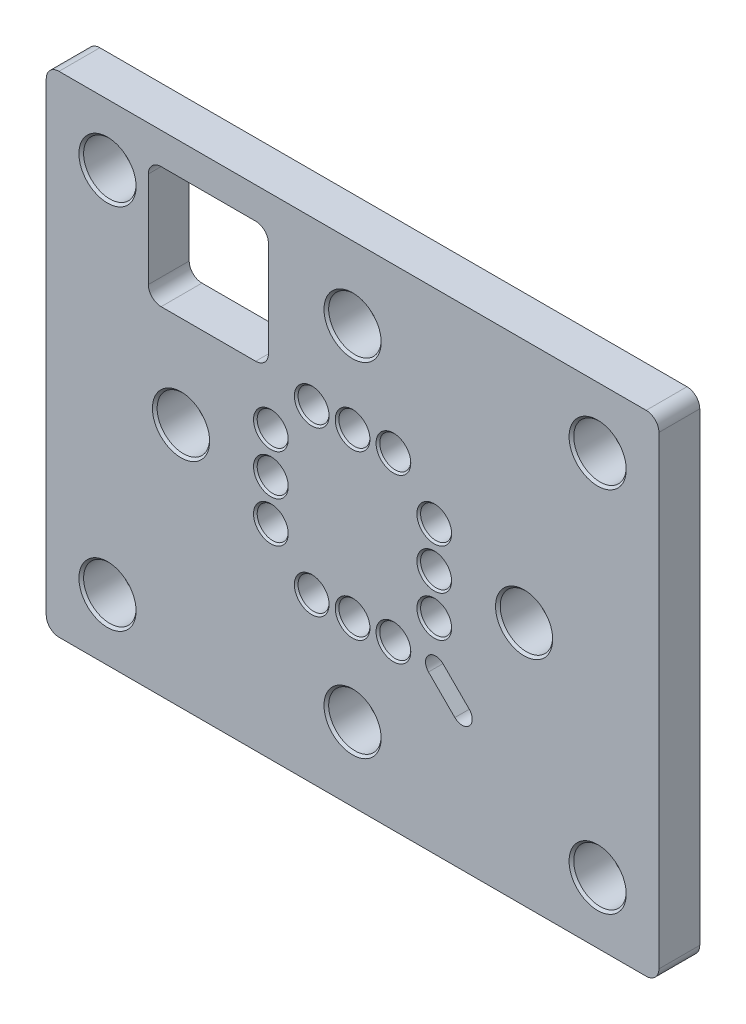
from build123d import *

# Parameters (mm, degrees)
SKETCH1_W                            = 38.1
SKETCH1_H                            = 30.48
BOSS_EXTRUDE1_DEPTH                  = 2.54
F_48_0_076_DIAMETER_HOLE1_AT_2_COUNT = 2
F_48_0_076_DIAMETER_HOLE1_AT_2_PITCH = 2.54
F_48_0_076_DIAMETER_HOLE1_AT_3_COUNT = 2
F_48_0_076_DIAMETER_HOLE1_AT_3_PITCH = 2.54
CIRPATTERN1_COUNT                    = 4
F_4_CLEARANCE_HOLE3_AT_2_COUNT       = 2
F_4_CLEARANCE_HOLE3_AT_2_PITCH       = 30.48
F_4_CLEARANCE_HOLE3_AT_3_COUNT       = 2
F_4_CLEARANCE_HOLE3_AT_3_PITCH       = 38.1
F_4_CLEARANCE_HOLE3_AT_4_COUNT       = 2
F_4_CLEARANCE_HOLE3_AT_4_PITCH       = 22.86
SKETCH10_W                           = 7.4676
SKETCH10_H                           = 7.5438
CUT_EXTRUDE1_DEPTH                   = 3.54
FILLET1_R                            = 0.79375
CUT_EXTRUDE2_DEPTH                   = 3.54


with BuildPart() as part:
    # Sketch1 → Boss-Extrude1 (new body)
    with BuildSketch(Plane.XY):
        Rectangle(SKETCH1_W, SKETCH1_H)
    extrude(amount=-BOSS_EXTRUDE1_DEPTH)

    # Sketch2 → 48 _0.076_ Diameter Hole1 (revolve, cut)
    with BuildSketch(Plane(origin=(0, 5.08, 0), x_dir=(0, -1, 0), z_dir=(1, 0, 0))):
        Polygon((0, 0), (0, 2.54), (1.0795, 2.54), (0.9652, 2.4257), (0.9652, 0.1143), (1.0795, 0), align=None)
    f_48_0_076_diameter_hole1 = revolve(axis=Axis((0, 5.08, 6.35), (0, 0, -1)), mode=Mode.SUBTRACT)

    # 48 _0.076_ Diameter Hole1 at 2: 48 _0.076_ Diameter Hole1 ×2
    with Locations(*[(i * F_48_0_076_DIAMETER_HOLE1_AT_2_PITCH, 0, 0) for i in range(1, F_48_0_076_DIAMETER_HOLE1_AT_2_COUNT)]):
        add(f_48_0_076_diameter_hole1, mode=Mode.SUBTRACT)

    # 48 _0.076_ Diameter Hole1 at 3: 48 _0.076_ Diameter Hole1 ×2
    with Locations(*[(-i * F_48_0_076_DIAMETER_HOLE1_AT_3_PITCH, 0, 0) for i in range(1, F_48_0_076_DIAMETER_HOLE1_AT_3_COUNT)]):
        add(f_48_0_076_diameter_hole1, mode=Mode.SUBTRACT)

    # Sketch4 → 4 Clearance Hole4 (revolve, cut)
    with BuildSketch(Plane(origin=(0, 10.668, 0), x_dir=(0, -1, 0), z_dir=(1, 0, 0))):
        Polygon((0, 0), (0, 2.54), (1.778, 2.54), (1.63195, 2.39395), (1.63195, 0.14605), (1.778, 0), align=None)
    f_4_clearance_hole4 = revolve(axis=Axis((0, 10.668, 6.35), (0, 0, -1)), mode=Mode.SUBTRACT)

    # CirPattern1: 48 _0.076_ Diameter Hole1, 4 Clearance Hole4 ×4 about axis
    cirpattern1_axis = Axis((0, 0, 0), (0, 0, 1))
    add([f_48_0_076_diameter_hole1.rotate(cirpattern1_axis, i * 360 / CIRPATTERN1_COUNT) for i in range(1, CIRPATTERN1_COUNT)], mode=Mode.SUBTRACT)
    add([f_4_clearance_hole4.rotate(cirpattern1_axis, i * 360 / CIRPATTERN1_COUNT) for i in range(1, CIRPATTERN1_COUNT)], mode=Mode.SUBTRACT)

    # CirPattern1 copy 1 sketch → CirPattern1 copy 1 (revolve, cut)
    with BuildSketch(Plane(origin=(-5.08, 2.54, 0), x_dir=(1, 0, 0), z_dir=(0, 1, 0))):
        Polygon((0, 0), (0, 2.54), (1.0795, 2.54), (0.9652, 2.4257), (0.9652, 0.1143), (1.0795, 0), align=None)
    revolve(axis=Axis((-5.08, 2.54, 6.35), (0, 0, -1)), mode=Mode.SUBTRACT)

    # CirPattern1 copy 2 sketch → CirPattern1 copy 2 (revolve, cut)
    with BuildSketch(Plane(origin=(-2.54, -5.08, 0), x_dir=(0, 1, 0), z_dir=(-1, 0, 0))):
        Polygon((0, 0), (0, 2.54), (1.0795, 2.54), (0.9652, 2.4257), (0.9652, 0.1143), (1.0795, 0), align=None)
    revolve(axis=Axis((-2.54, -5.08, 6.35), (0, 0, -1)), mode=Mode.SUBTRACT)

    # CirPattern1 copy 3 sketch → CirPattern1 copy 3 (revolve, cut)
    with BuildSketch(Plane(origin=(5.08, -2.54, 0), x_dir=(-1, 0, 0), z_dir=(0, -1, 0))):
        Polygon((0, 0), (0, 2.54), (1.0795, 2.54), (0.9652, 2.4257), (0.9652, 0.1143), (1.0795, 0), align=None)
    revolve(axis=Axis((5.08, -2.54, 6.35), (0, 0, -1)), mode=Mode.SUBTRACT)

    # CirPattern1 copy 4 sketch → CirPattern1 copy 4 (revolve, cut)
    with BuildSketch(Plane(origin=(-5.08, -2.54, 0), x_dir=(1, 0, 0), z_dir=(0, 1, 0))):
        Polygon((0, 0), (0, 2.54), (1.0795, 2.54), (0.9652, 2.4257), (0.9652, 0.1143), (1.0795, 0), align=None)
    revolve(axis=Axis((-5.08, -2.54, 6.35), (0, 0, -1)), mode=Mode.SUBTRACT)

    # CirPattern1 copy 5 sketch → CirPattern1 copy 5 (revolve, cut)
    with BuildSketch(Plane(origin=(2.54, -5.08, 0), x_dir=(0, 1, 0), z_dir=(-1, 0, 0))):
        Polygon((0, 0), (0, 2.54), (1.0795, 2.54), (0.9652, 2.4257), (0.9652, 0.1143), (1.0795, 0), align=None)
    revolve(axis=Axis((2.54, -5.08, 6.35), (0, 0, -1)), mode=Mode.SUBTRACT)

    # CirPattern1 copy 6 sketch → CirPattern1 copy 6 (revolve, cut)
    with BuildSketch(Plane(origin=(5.08, 2.54, 0), x_dir=(-1, 0, 0), z_dir=(0, -1, 0))):
        Polygon((0, 0), (0, 2.54), (1.0795, 2.54), (0.9652, 2.4257), (0.9652, 0.1143), (1.0795, 0), align=None)
    revolve(axis=Axis((5.08, 2.54, 6.35), (0, 0, -1)), mode=Mode.SUBTRACT)

    # Sketch8 → 4 Clearance Hole3 (revolve, cut)
    with BuildSketch(Plane(origin=(-15.24, 11.43, 0), x_dir=(0, -1, 0), z_dir=(1, 0, 0))):
        Polygon((0, 0), (0, 2.54), (1.778, 2.54), (1.63195, 2.39395), (1.63195, 0.14605), (1.778, 0), align=None)
    f_4_clearance_hole3 = revolve(axis=Axis((-15.24, 11.43, 6.35), (0, 0, -1)), mode=Mode.SUBTRACT)

    # 4 Clearance Hole3 at 2: 4 Clearance Hole3 ×2
    with Locations(*[(i * F_4_CLEARANCE_HOLE3_AT_2_PITCH, 0, 0) for i in range(1, F_4_CLEARANCE_HOLE3_AT_2_COUNT)]):
        add(f_4_clearance_hole3, mode=Mode.SUBTRACT)

    # 4 Clearance Hole3 at 3: 4 Clearance Hole3 ×2
    with Locations(*[Vector(0.8, -0.6, 0) * (i * F_4_CLEARANCE_HOLE3_AT_3_PITCH) for i in range(1, F_4_CLEARANCE_HOLE3_AT_3_COUNT)]):
        add(f_4_clearance_hole3, mode=Mode.SUBTRACT)

    # 4 Clearance Hole3 at 4: 4 Clearance Hole3 ×2
    with Locations(*[(0, -i * F_4_CLEARANCE_HOLE3_AT_4_PITCH, 0) for i in range(1, F_4_CLEARANCE_HOLE3_AT_4_COUNT)]):
        add(f_4_clearance_hole3, mode=Mode.SUBTRACT)

    # Sketch10 → Cut-Extrude1 (cut, through all)
    with BuildSketch(Plane(origin=(0, 0, -2.54), x_dir=(-1, 0, 0), z_dir=(0, 0, -1))):
        with Locations((8.9662, 9.5123)):
            Rectangle(SKETCH10_W, SKETCH10_H)
    extrude(amount=-CUT_EXTRUDE1_DEPTH, mode=Mode.SUBTRACT)

    # Fillet1
    fillet1_edges = [part.edges().sort_by_distance(p)[0] for p in [
        (-12.7, 13.2842, -1.27),
        (-12.7, 5.7404, -1.27),
        (-5.2324, 5.7404, -1.27),
        (-5.2324, 13.2842, -1.27),
        (19.05, -15.24, -1.27),
        (-19.05, -15.24, -1.27),
        (-19.05, 15.24, -1.27),
        (19.05, 15.24, -1.27),
    ]]
    fillet(fillet1_edges, radius=FILLET1_R)

    # Sketch11 → Cut-Extrude2 (cut, through all)
    with BuildSketch(Plane.XY):
        with BuildLine():
            Line((5.619985846, -4.721960234), (7.256475174, -6.358449562))
            ThreePointArc((7.256475174, -6.358449562), (7.256475174, -7.256475174), (6.358449562, -7.256475174))
            Line((6.358449562, -7.256475174), (4.721960234, -5.619985846))
            ThreePointArc((4.721960234, -5.619985846), (4.721960234, -4.721960234), (5.619985846, -4.721960234))
        make_face()
    extrude(amount=-CUT_EXTRUDE2_DEPTH, mode=Mode.SUBTRACT)


solid = part.part
